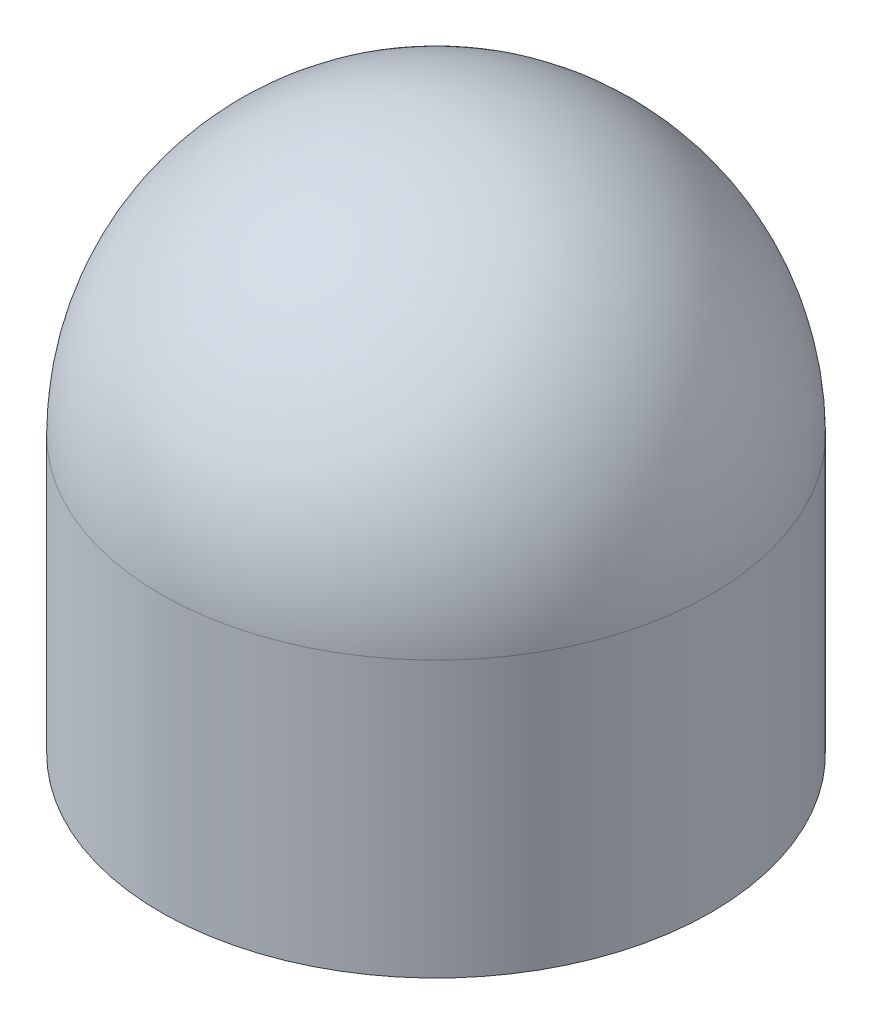
from build123d import *


with BuildPart() as part:
    # Sketch1 → Revolve1 (revolve)
    with BuildSketch(Plane.XY):
        with BuildLine():
            Line((0, 0), (40, 0))
            Line((40, 0), (40, 40))
            ThreePointArc((40, 40), (28.284271247, 68.284271247), (0, 80))
            Line((0, 80), (0, 0))
        make_face()
    revolve(axis=Axis((0, 0, 0), (0, 1, 0)))


solid = part.part
